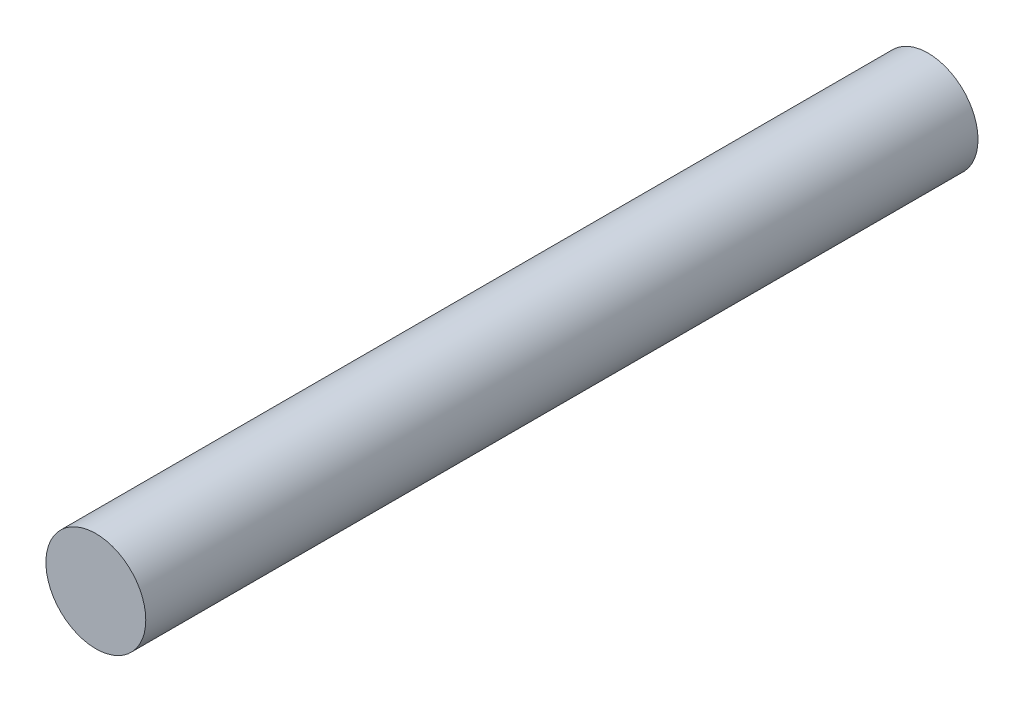
from build123d import *

# Parameters (mm, degrees)
ESBO_O1_R                = 1.5
RESSALTO_EXTRUS_O1_DEPTH = 25


with BuildPart() as part:
    # Esboço1 → Ressalto-extrusão1 (new body)
    with BuildSketch(Plane.XY):
        Circle(ESBO_O1_R)
    extrude(amount=RESSALTO_EXTRUS_O1_DEPTH)


solid = part.part
